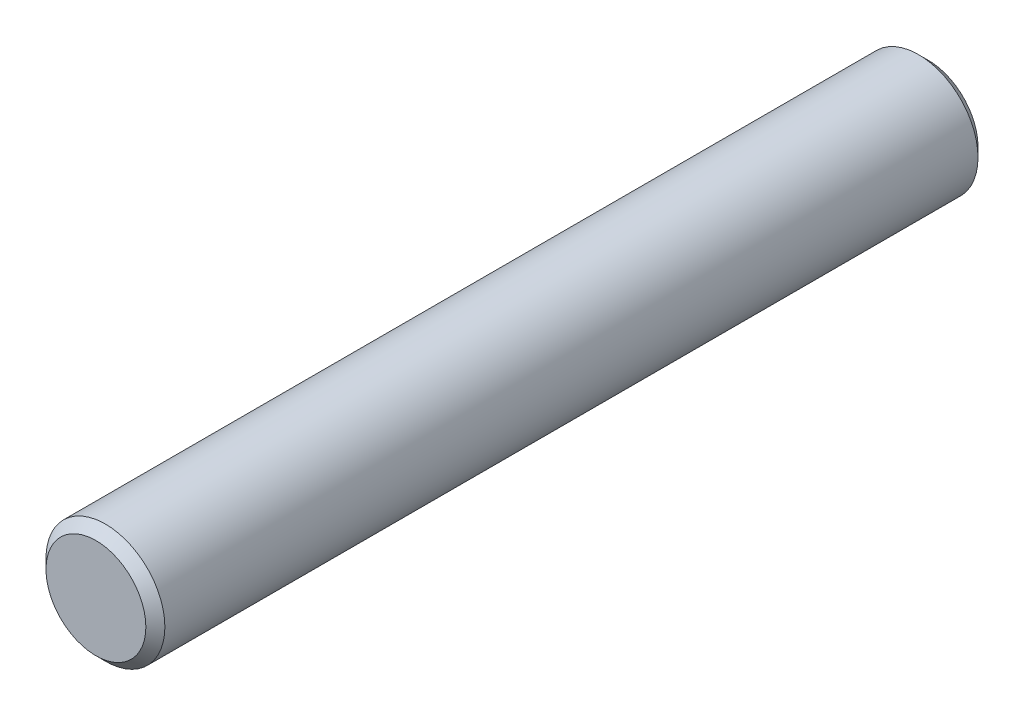
from build123d import *

# Parameters (mm, degrees)
SKETCH1_R           = 1.5875
BOSS_EXTRUDE1_DEPTH = 22.225
CHAMFER1_SIZE       = 0.254


with BuildPart() as part:
    # Sketch1 → Boss-Extrude1 (new body)
    with BuildSketch(Plane.XY):
        Circle(SKETCH1_R)
    extrude(amount=-BOSS_EXTRUDE1_DEPTH)

    # Chamfer1
    chamfer1_edges = [part.edges().sort_by_distance(p)[0] for p in [
        (-1.5875, 0, -22.225),
        (-1.5875, 0, 0),
    ]]
    chamfer(chamfer1_edges, length=CHAMFER1_SIZE)


solid = part.part
